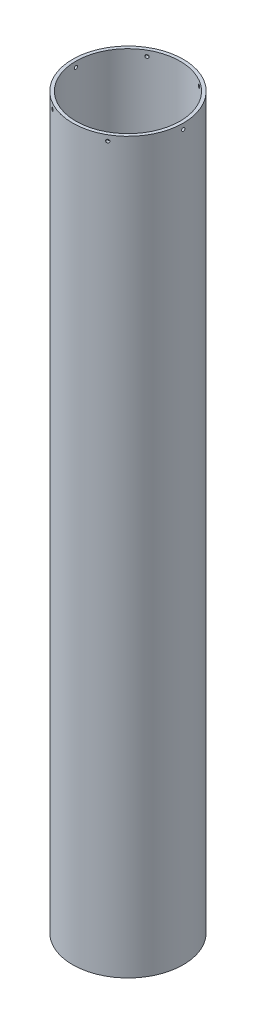
from build123d import *

# Parameters (mm, degrees)
SKETCH1_R           = 53.975
SKETCH1_R_2         = 50.8
BOSS_EXTRUDE1_DEPTH = 711.2
SKETCH2_R           = 1.5875
CUT_EXTRUDE1_DEPTH  = 54.975
CIRPATTERN1_COUNT   = 3


with BuildPart() as part:
    # Sketch1 → Boss-Extrude1 (new body)
    with BuildSketch(Plane(origin=(0, 0, 0), x_dir=(1, 0, 0), z_dir=(0, 1, 0))):
        Circle(SKETCH1_R)
        Circle(SKETCH1_R_2, mode=Mode.SUBTRACT)
    extrude(amount=BOSS_EXTRUDE1_DEPTH)

    # Sketch2 → Cut-Extrude1 (cut, symmetric)
    with BuildSketch(Plane(origin=(0, 0, 0), x_dir=(0, 0, -1), z_dir=(1, 0, 0))):
        with Locations((0, 705.84695)):
            Circle(SKETCH2_R)
    cut_extrude1 = extrude(amount=CUT_EXTRUDE1_DEPTH, both=True, mode=Mode.SUBTRACT)

    # CirPattern1: Cut-Extrude1 ×3 about axis
    cirpattern1_axis = Axis((0, 711.2, 0), (0, 1, 0))
    for i in range(1, CIRPATTERN1_COUNT):
        add(cut_extrude1.rotate(cirpattern1_axis, i * 360 / CIRPATTERN1_COUNT), mode=Mode.SUBTRACT)


solid = part.part
